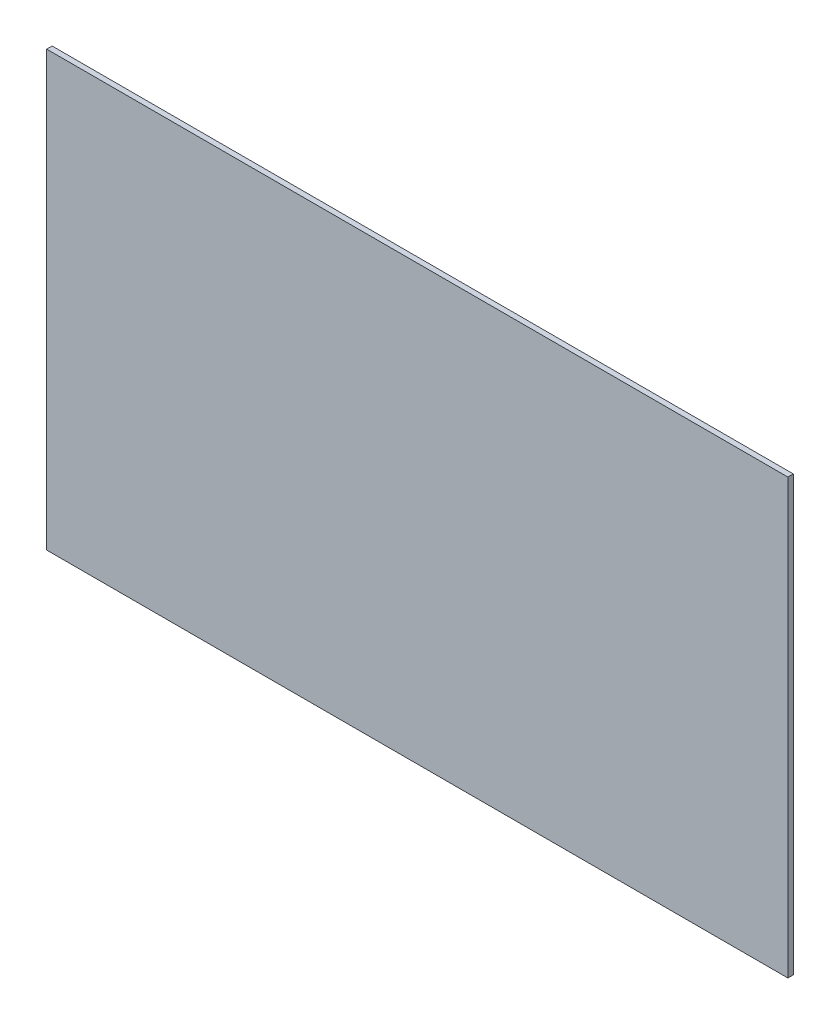
from build123d import *

# Parameters (mm, degrees)
SKETCH1_W           = 410
SKETCH1_H           = 240
BOSS_EXTRUDE1_DEPTH = 1.5


with BuildPart() as part:
    # Sketch1 → Boss-Extrude1 (new body, symmetric)
    with BuildSketch(Plane.XY):
        Rectangle(SKETCH1_W, SKETCH1_H)
    extrude(amount=BOSS_EXTRUDE1_DEPTH, both=True)


solid = part.part
